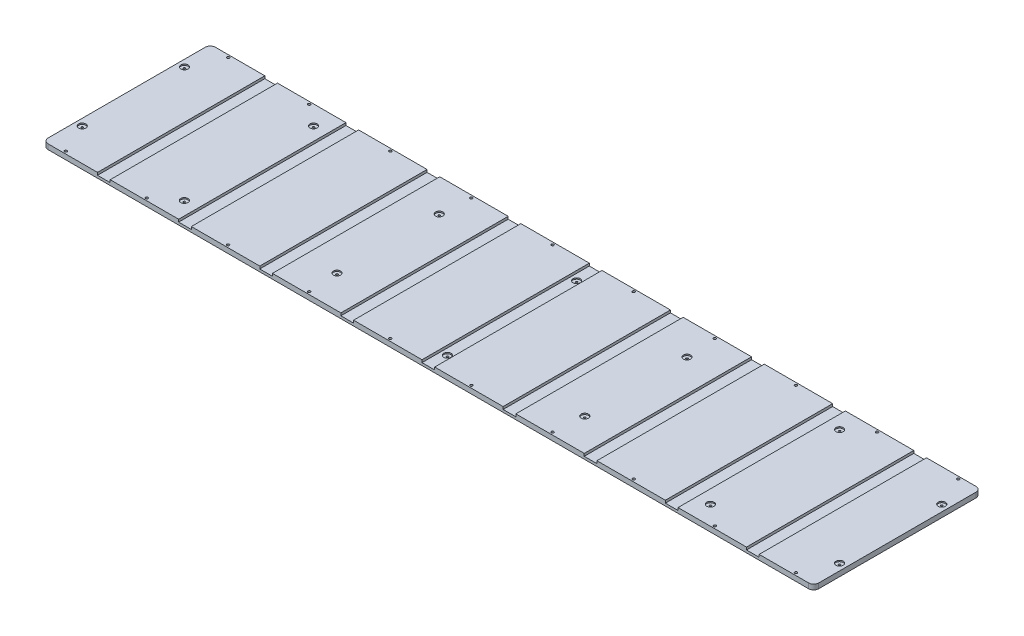
from build123d import *

# Parameters (mm, degrees)
SKETCH1_W                                           = 1930.4
SKETCH1_H                                           = 419.1
BOSS_EXTRUDE1_DEPTH                                 = 12.7
FILLET1_R                                           = 12.7
SKETCH8_W                                           = 31.75
SKETCH8_H                                           = 419.1
CUT_EXTRUDE3_DEPTH                                  = 6.35
F_1_4_0_25_DIAMETER_HOLE1_D                         = 6.35
CBORE_FOR_10_SOCKET_HEAD_CAP_SCREW1_D               = 4.9022
CBORE_FOR_10_SOCKET_HEAD_CAP_SCREW1_CBORE_D         = 18.0975
CBORE_FOR_10_SOCKET_HEAD_CAP_SCREW1_CBORE_DEPTH     = 3.175
CBORE_FOR_10_BINDING_HEAD_MACHINE_SCREW_D           = 4.9022
CBORE_FOR_10_BINDING_HEAD_MACHINE_SCREW_CBORE_D     = 18.0975
CBORE_FOR_10_BINDING_HEAD_MACHINE_SCREW_CBORE_DEPTH = 3.175


with BuildPart() as part:
    # Sketch1 → Boss-Extrude1 (new body)
    with BuildSketch(Plane(origin=(0, 0, 0), x_dir=(1, 0, 0), z_dir=(0, 1, 0))):
        with Locations((965.2, 209.55)):
            Rectangle(SKETCH1_W, SKETCH1_H)
    extrude(amount=BOSS_EXTRUDE1_DEPTH)

    # Fillet1
    fillet1_edges = [part.edges().sort_by_distance(p)[0] for p in [
        (0, 6.35, -419.1),
        (1930.4, 6.35, -419.1),
        (1930.4, 6.35, 0),
        (0, 6.35, 0),
    ]]
    fillet(fillet1_edges, radius=FILLET1_R)

    # Sketch8 → Cut-Extrude3 (cut)
    with BuildSketch(Plane(origin=(0, 12.7, 0), x_dir=(1, 0, 0), z_dir=(0, 1, 0))):
        with Locations((152.4, 209.55)):
            Rectangle(SKETCH8_W, SKETCH8_H)
        with Locations((355.6, 209.55)):
            Rectangle(SKETCH8_W, SKETCH8_H)
        with Locations((558.8, 209.55)):
            Rectangle(SKETCH8_W, SKETCH8_H)
        with Locations((762, 209.55)):
            Rectangle(SKETCH8_W, SKETCH8_H)
        with Locations((965.2, 209.55)):
            Rectangle(SKETCH8_W, SKETCH8_H)
        with Locations((1168.4, 209.55)):
            Rectangle(SKETCH8_W, SKETCH8_H)
        with Locations((1371.6, 209.55)):
            Rectangle(SKETCH8_W, SKETCH8_H)
        with Locations((1574.8, 209.55)):
            Rectangle(SKETCH8_W, SKETCH8_H)
        with Locations((1778, 209.55)):
            Rectangle(SKETCH8_W, SKETCH8_H)
    extrude(amount=-CUT_EXTRUDE3_DEPTH, mode=Mode.SUBTRACT)

    # 1/4 (0.25) Diameter Hole1 (through all)
    with Locations(Plane(origin=(0, 12.7, 0), x_dir=(1, 0, 0), z_dir=(0, 1, 0))):
        with Locations((254, 6.35), (457.2, 6.35), (660.4, 6.35), (863.6, 6.35), (1066.8, 6.35), (1270, 6.35), (1473.2, 6.35), (1676.4, 6.35), (50.8, 6.35), (1879.6, 6.35), (1676.4, 412.75), (1879.6, 412.75), (50.8, 412.75), (1473.2, 412.75), (1270, 412.75), (1066.8, 412.75), (863.6, 412.75), (660.4, 412.75), (457.2, 412.75), (254, 412.75)):
            Hole(F_1_4_0_25_DIAMETER_HOLE1_D / 2)

    # CBORE for #10 Socket Head Cap Screw1 (through all)
    with Locations(Plane(origin=(0, 12.7, 0), x_dir=(1, 0, 0), z_dir=(0, 1, 0))):
        with Locations((16.66875, 337.566), (16.66875, 81.534), (306.324, 47.752), (306.324, 371.348), (654.84375, 337.566), (654.84375, 81.534), (965.2, 371.348), (965.2, 47.752), (1275.55625, 81.534), (1275.55625, 337.566), (1624.076, 371.348), (1624.076, 47.752), (1913.73125, 81.534), (1913.73125, 337.566)):
            CounterBoreHole(CBORE_FOR_10_SOCKET_HEAD_CAP_SCREW1_D / 2, CBORE_FOR_10_SOCKET_HEAD_CAP_SCREW1_CBORE_D / 2, CBORE_FOR_10_SOCKET_HEAD_CAP_SCREW1_CBORE_DEPTH)

    # CBORE for #10 Binding Head Machine Screw1 (through all)
    with Locations(Plane(origin=(0, 6.35, 0), x_dir=(1, 0, 0), z_dir=(0, 1, 0))):
        with Locations((965.2, 371.348), (965.2, 47.752)):
            CounterBoreHole(CBORE_FOR_10_BINDING_HEAD_MACHINE_SCREW_D / 2, CBORE_FOR_10_BINDING_HEAD_MACHINE_SCREW_CBORE_D / 2, CBORE_FOR_10_BINDING_HEAD_MACHINE_SCREW_CBORE_DEPTH)


solid = part.part
